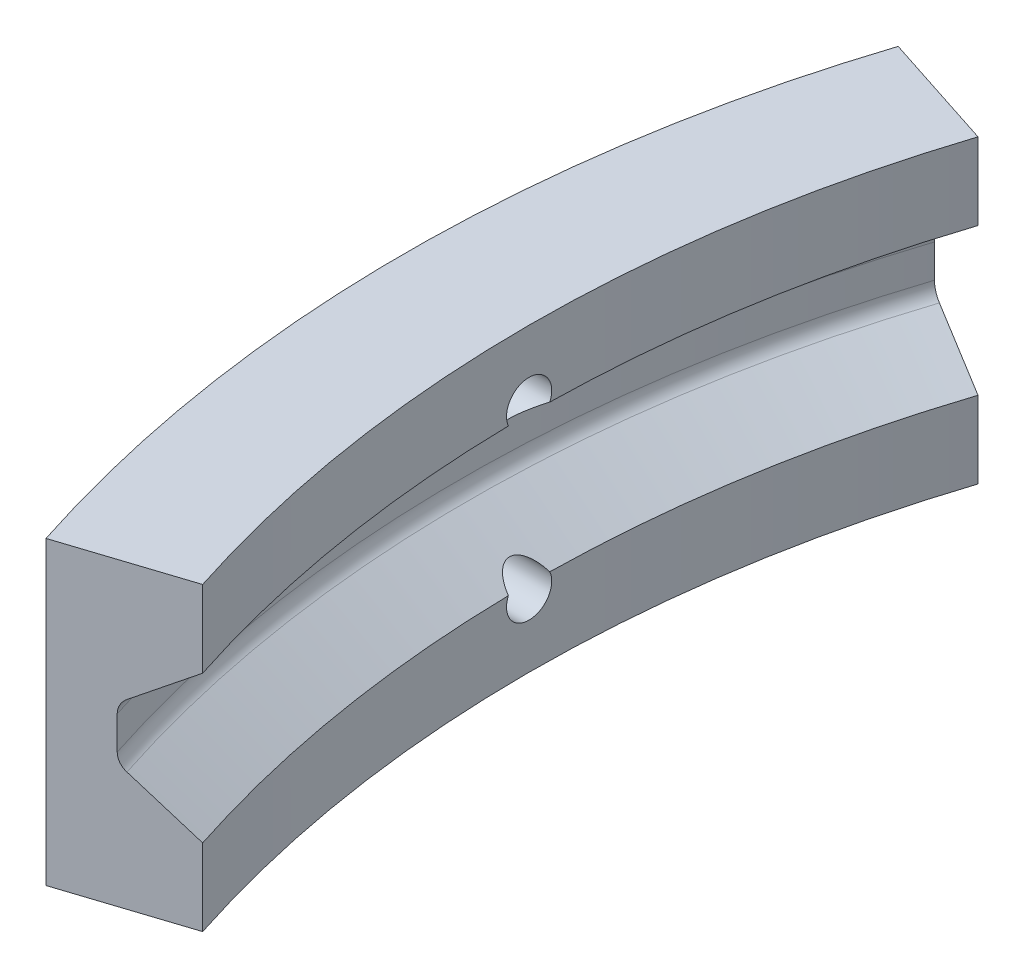
from build123d import *

# Parameters (mm, degrees)
ROTATION2_ANGLE                      = 36
SCHNITT_LINEAR_AUSTRAGEN2_DEPTH      = 3.4
SCHNITT_LINEAR_AUSTRAGEN2_DEPTH_BACK = 21.661746393
SKIZZE3_R                            = 1


with BuildPart() as part:
    # Skizze2 → Rotation2 (revolve, symmetric)
    with BuildSketch(Plane.XY) as rotation2_sk:
        with BuildLine():
            Line((-55.5, 3.250518846), (-58.158861149, 1.388764226))
            ThreePointArc((-58.158861149, 1.388764226), (-58.409608667, 1.102841481), (-58.5, 0.73344259))
            Line((-58.5, 0.73344259), (-58.5, -0.73344259))
            ThreePointArc((-58.5, -0.73344259), (-58.409608667, -1.102841481), (-58.158861149, -1.388764226))
            Line((-58.158861149, -1.388764226), (-55.5, -3.250518846))
            Line((-55.5, -3.250518846), (-55.5, -6.65))
            Line((-55.5, -6.65), (-61, -6.65))
            Line((-61, -6.65), (-61, 6.65))
            Line((-61, 6.65), (-55.5, 6.65))
            Line((-55.5, 6.65), (-55.5, 3.250518846))
        make_face()
    revolve(axis=Axis((0, 6.707883832, 0), (0, -1, 0)), revolution_arc=ROTATION2_ANGLE / 2)
    revolve(rotation2_sk.sketch, axis=Axis((0, 6.707883832, 0), (0, 1, 0)), revolution_arc=ROTATION2_ANGLE / 2)

    # Skizze3 → Schnitt-Linear austragen2 (cut, two sides: drawn at the far end of the back side and taken through both)
    with BuildSketch(Plane(origin=(-58.014447494, 0, 0), x_dir=(0, 0, -1), z_dir=(1, 0, 0)).offset(-SCHNITT_LINEAR_AUSTRAGEN2_DEPTH_BACK)):
        with Locations((0, 3.65)):
            Circle(SKIZZE3_R)
        with Locations((0, -3.65)):
            Circle(SKIZZE3_R)
    extrude(amount=SCHNITT_LINEAR_AUSTRAGEN2_DEPTH + SCHNITT_LINEAR_AUSTRAGEN2_DEPTH_BACK, mode=Mode.SUBTRACT)


solid = part.part
